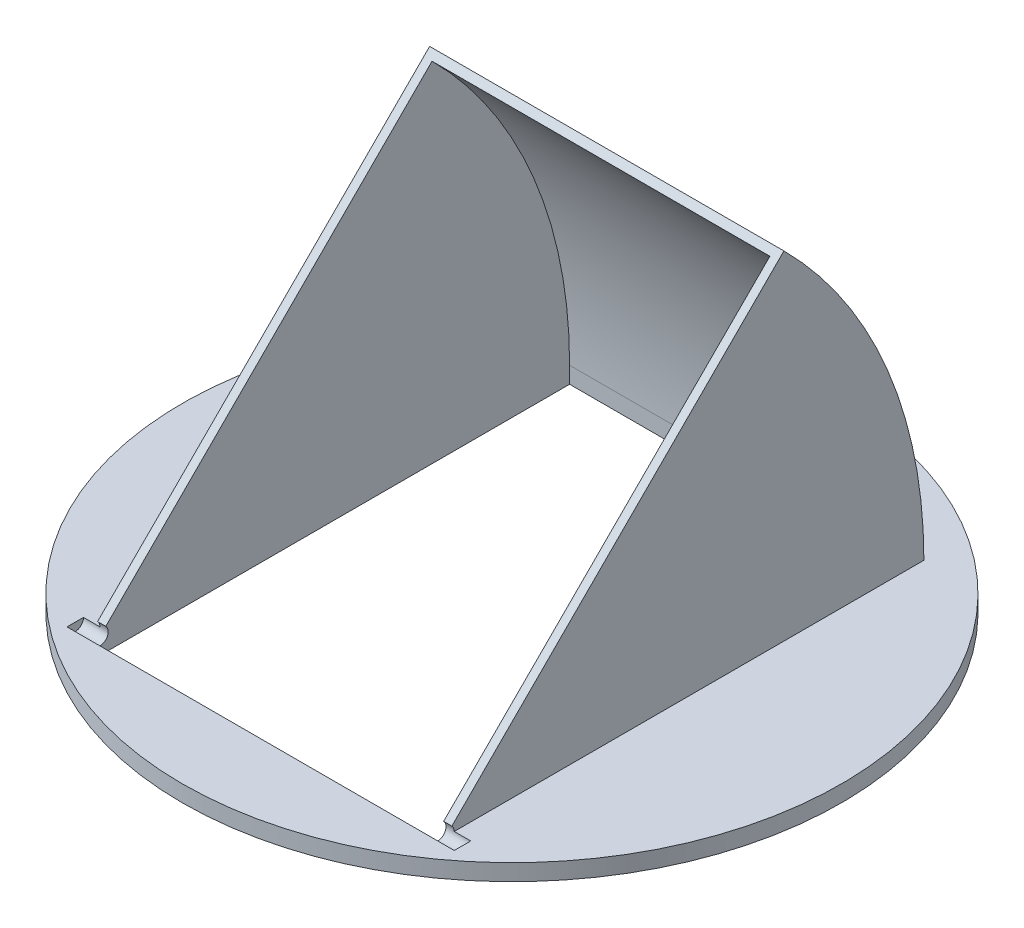
from build123d import *

# Parameters (mm, degrees)
SKETCH1_R               = 127
BOSS_EXTRUDE1_DEPTH     = 6.35
SKETCH2_W               = 136.525
SKETCH2_H               = 187.325
SKETCH2_W_2             = 130.175
SKETCH2_H_2             = 180.975
BOSS_EXTRUDE2_DEPTH     = 180.975
CUT_EXTRUDE1_REACH      = 197.262
CUT_EXTRUDE2_REACH      = 222.663
SKETCH6_W               = 130.175
SKETCH6_H               = 180.975
CUT_EXTRUDE3_REACH      = 8.35
SKETCH7_W               = 130.175
SKETCH7_H               = 180.975
BOSS_EXTRUDE3_DEPTH     = 136.525
CUT_EXTRUDE4_DEPTH      = 136.525
SKETCH15_R              = 3.175
CUT_EXTRUDE5_DEPTH      = 6.35
CUT_EXTRUDE5_DEPTH_BACK = 142.875


with BuildPart() as part:
    # Sketch1 → Boss-Extrude1 (new body)
    with BuildSketch(Plane(origin=(0, 0, 0), x_dir=(1, 0, 0), z_dir=(0, 1, 0))):
        Circle(SKETCH1_R)
    extrude(amount=BOSS_EXTRUDE1_DEPTH)

    # Sketch2 → Boss-Extrude2 (add)
    with BuildSketch(Plane(origin=(0, 6.35, 0), x_dir=(1, 0, 0), z_dir=(0, 1, 0))):
        Rectangle(SKETCH2_W, SKETCH2_H)
        Rectangle(SKETCH2_W_2, SKETCH2_H_2, mode=Mode.SUBTRACT)
    extrude(amount=BOSS_EXTRUDE2_DEPTH)

    # Sketch3 → Cut-Extrude1 (cut, up to next)
    with BuildSketch(Plane(origin=(68.2625, 0, 0), x_dir=(0, 0, -1), z_dir=(1, 0, 0)), mode=Mode.PRIVATE) as cut_extrude1_sk1:
        with BuildLine():
            Line((-93.6625, 187.325), (93.6625, 187.325))
            Line((93.6625, 187.325), (93.6625, 6.35))
            Line((93.6625, 6.35), (87.3125, 6.35))
            ThreePointArc((87.3125, 6.35), (34.306149725, 134.318649725), (-93.6625, 187.325))
        make_face()
    cut_extrude1_tool1 = extrude(cut_extrude1_sk1.sketch, amount=-CUT_EXTRUDE1_REACH, mode=Mode.PRIVATE) & part.part
    add(cut_extrude1_tool1.solids().sort_by_distance((68.2625, 139.865797, -53.015255))[0], mode=Mode.SUBTRACT)

    # Sketch6 → Cut-Extrude2 (cut, up to next)
    with BuildSketch(Plane.XY.offset(93.6625), mode=Mode.PRIVATE) as cut_extrude2_sk1:
        with Locations((0, 96.8375)):
            Rectangle(SKETCH6_W, SKETCH6_H)
    cut_extrude2_tool1 = extrude(cut_extrude2_sk1.sketch, amount=-CUT_EXTRUDE2_REACH, mode=Mode.PRIVATE) & part.part
    add(cut_extrude2_tool1.solids().sort_by_distance((0, 96.8375, 93.6625))[0], mode=Mode.SUBTRACT)

    # Sketch7 → Cut-Extrude3 (cut, up to next)
    with BuildSketch(Plane(origin=(0, 6.35, 0), x_dir=(1, 0, 0), z_dir=(0, 1, 0)), mode=Mode.PRIVATE) as cut_extrude3_sk1:
        with Locations((0, -3.175)):
            Rectangle(SKETCH7_W, SKETCH7_H)
    cut_extrude3_tool1 = extrude(cut_extrude3_sk1.sketch, amount=-CUT_EXTRUDE3_REACH, mode=Mode.PRIVATE) & part.part
    add(cut_extrude3_tool1.solids().sort_by_distance((0, 6.35, 3.175))[0], mode=Mode.SUBTRACT)

    # Sketch10 → Boss-Extrude3 (add)
    with BuildSketch(Plane(origin=(68.2625, 0, 0), x_dir=(0, 0, -1), z_dir=(1, 0, 0))):
        with BuildLine():
            Line((-93.6625, 187.325), (-93.6625, 190.5))
            ThreePointArc((-93.6625, 190.5), (36.551213756, 136.563713756), (90.4875, 6.35))
            Line((90.4875, 6.35), (87.3125, 6.35))
            ThreePointArc((87.3125, 6.35), (34.306149725, 134.318649725), (-93.6625, 187.325))
        make_face()
    extrude(amount=-BOSS_EXTRUDE3_DEPTH)

    # Sketch12 → Cut-Extrude4 (cut)
    with BuildSketch(Plane(origin=(68.2625, 0, 0), x_dir=(0, 0, -1), z_dir=(1, 0, 0))):
        with BuildLine():
            Line((-93.6625, 6.35), (36.551213756, 136.563713756))
            ThreePointArc((36.551213756, 136.563713756), (-23.19134593, 176.482415912), (-93.6625, 190.5))
            Line((-93.6625, 190.5), (-93.6625, 6.35))
        make_face()
    extrude(amount=-CUT_EXTRUDE4_DEPTH, mode=Mode.SUBTRACT)

    # Sketch15 → Cut-Extrude5 (cut, two sides)
    with BuildSketch(Plane(origin=(68.2625, 0, 0), x_dir=(0, 0, -1), z_dir=(1, 0, 0))) as cut_extrude5_sk:
        with Locations((-93.6625, 6.35)):
            Circle(SKETCH15_R)
    extrude(amount=CUT_EXTRUDE5_DEPTH, mode=Mode.SUBTRACT)
    extrude(cut_extrude5_sk.sketch, amount=-CUT_EXTRUDE5_DEPTH_BACK, mode=Mode.SUBTRACT)


solid = part.part
